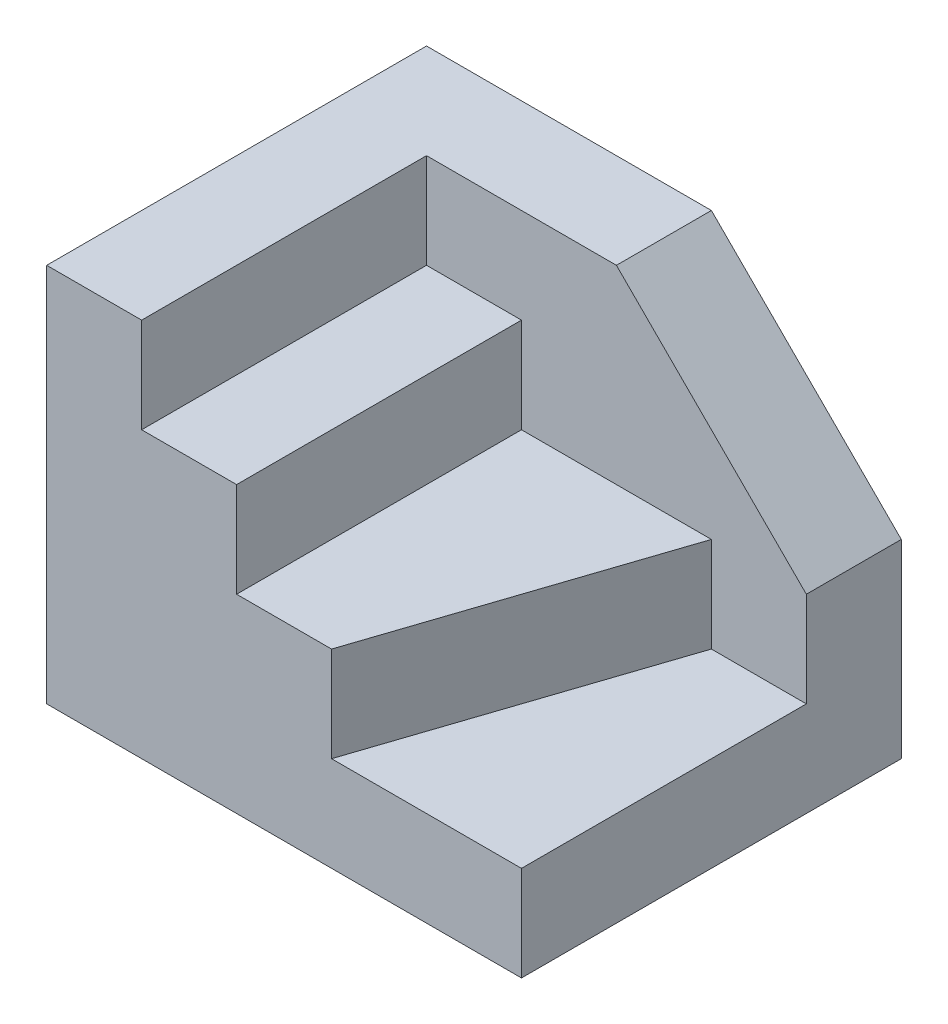
from build123d import *

# Parameters (mm, degrees)
SKETCH1_W           = 50
SKETCH1_H           = 40
BOSS_EXTRUDE1_DEPTH = 40
CUT_EXTRUDE1_DEPTH  = 30
CUT_EXTRUDE2_DEPTH  = 10
CUT_EXTRUDE3_DEPTH  = 10


with BuildPart() as part:
    # Sketch1 → Boss-Extrude1 (new body)
    with BuildSketch(Plane(origin=(0, 0, 0), x_dir=(1, 0, 0), z_dir=(0, 1, 0))):
        Rectangle(SKETCH1_W, SKETCH1_H)
    extrude(amount=BOSS_EXTRUDE1_DEPTH)

    # Sketch3 → Cut-Extrude1 (cut)
    with BuildSketch(Plane.XY.offset(20)):
        Polygon((-15, 40), (-15, 30), (-5, 30), (-5, 20), (25, 20), (25, 40), align=None)
    extrude(amount=-CUT_EXTRUDE1_DEPTH, mode=Mode.SUBTRACT)

    # Sketch4 → Cut-Extrude2 (cut)
    with BuildSketch(Plane(origin=(0, 20, 0), x_dir=(1, 0, 0), z_dir=(0, 1, 0))):
        Polygon((15, 10), (5, -20), (25, -20), (25, 10), align=None)
    extrude(amount=-CUT_EXTRUDE2_DEPTH, mode=Mode.SUBTRACT)

    # Sketch5 → Cut-Extrude3 (cut)
    with BuildSketch(Plane.XY.offset(-10)):
        Polygon((5, 40), (25, 20), (25, 40), align=None)
    extrude(amount=-CUT_EXTRUDE3_DEPTH, mode=Mode.SUBTRACT)


solid = part.part
